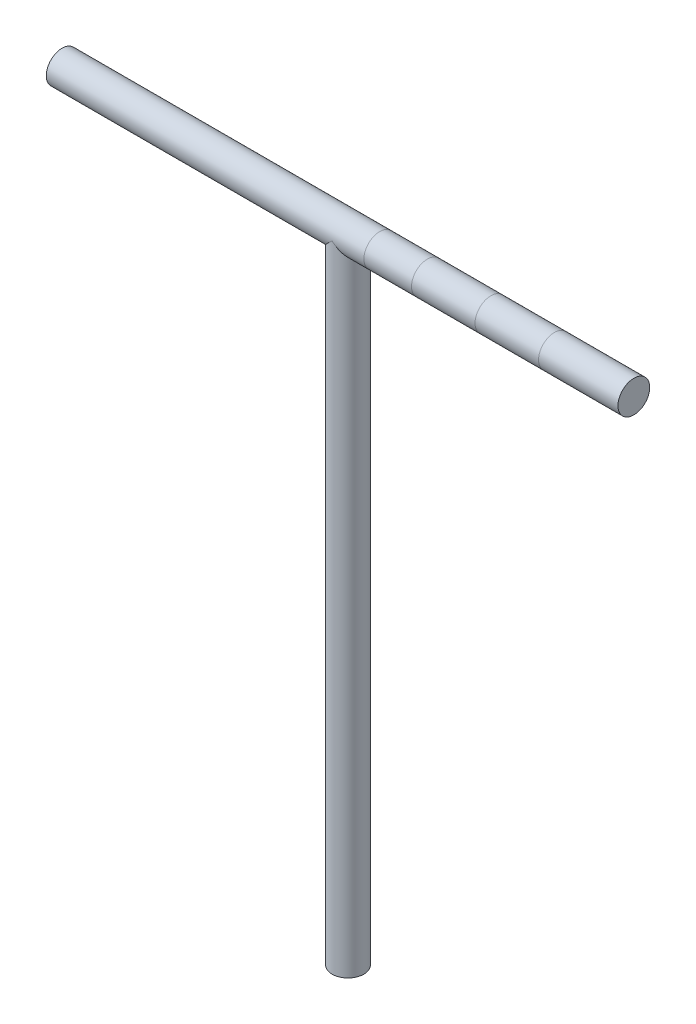
from build123d import *

# Parameters (mm, degrees)
SKETCH2_R           = 5
BOSS_EXTRUDE6_DEPTH = 90
SKETCH8_R           = 5
BOSS_EXTRUDE7_DEPTH = 200


with BuildPart() as part:
    # Sketch2 → Boss-Extrude6 (new body, symmetric)
    with BuildSketch(Plane(origin=(0, 0, 0), x_dir=(0, 0, -1), z_dir=(1, 0, 0))):
        Circle(SKETCH2_R)
    extrude(amount=BOSS_EXTRUDE6_DEPTH, both=True)

    # Sketch8 → Boss-Extrude7 (add)
    with BuildSketch(Plane(origin=(0, 0, 0), x_dir=(1, 0, 0), z_dir=(0, 1, 0))):
        Circle(SKETCH8_R)
    extrude(amount=-BOSS_EXTRUDE7_DEPTH)


solid = part.part
